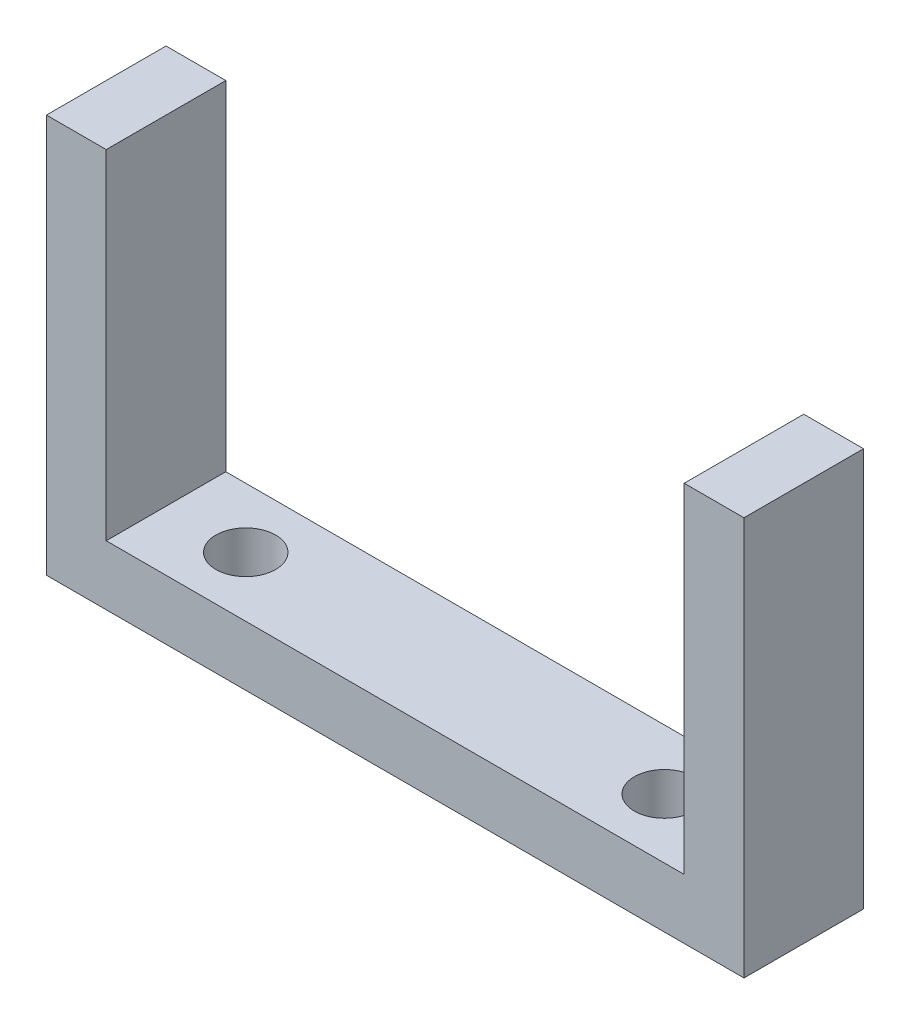
from build123d import *

# Parameters (mm, degrees)
BOSS_EXTRUDE1_DEPTH = 6
SKETCH2_R           = 1.5
CUT_EXTRUDE1_DEPTH  = 3


with BuildPart() as part:
    # Sketch1 → Boss-Extrude1 (new body)
    with BuildSketch(Plane.XY):
        Polygon((-32, 0), (-35, 0), (-35, -20), (0, -20), (0, 0), (-3, 0), (-3, -17), (-32, -17), align=None)
    extrude(amount=BOSS_EXTRUDE1_DEPTH)

    # Sketch2 → Cut-Extrude1 (cut)
    with BuildSketch(Plane.XZ.offset(20)):
        with Locations((-28, 3)):
            Circle(SKETCH2_R)
        with Locations((-7, 3)):
            Circle(SKETCH2_R)
    extrude(amount=-CUT_EXTRUDE1_DEPTH, mode=Mode.SUBTRACT)


solid = part.part
